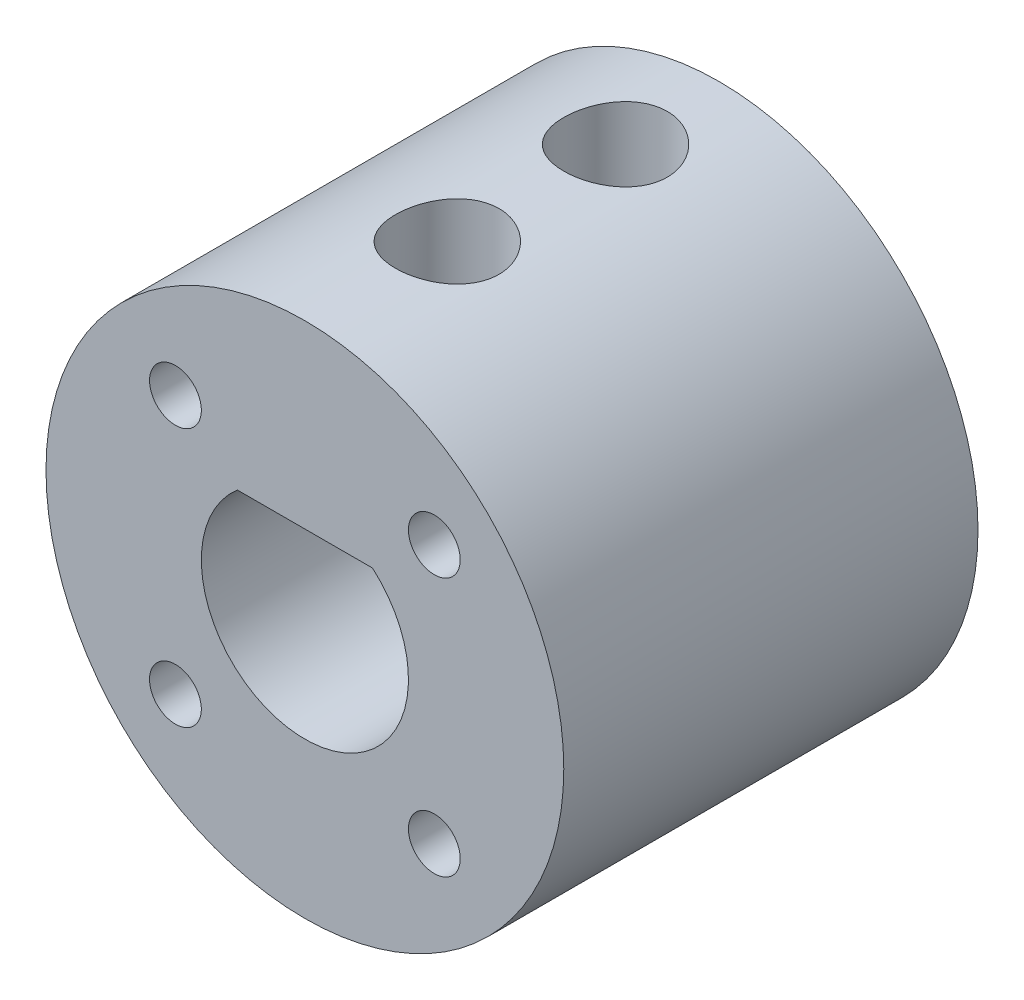
from build123d import *

# Parameters (mm, degrees)
CROQUIS1_R              = 10
SALIENTE_EXTRUIR1_DEPTH = 16
CROQUIS2_R              = 2
CORTAR_EXTRUIR1_DEPTH   = 20
CORTAR_EXTRUIR2_DEPTH   = 3
CROQUIS5_R              = 1
CORTAR_EXTRUIR3_DEPTH   = 14.0000001


with BuildPart() as part:
    # Croquis1 → Saliente-Extruir1 (new body)
    with BuildSketch(Plane.XY):
        Circle(CROQUIS1_R)
        with BuildLine():
            Line((2.611340652, 3.03), (-2.611340652, 3.03))
            ThreePointArc((-2.611340652, 3.03), (0, -4), (2.611340652, 3.03))
        make_face(mode=Mode.SUBTRACT)
    extrude(amount=SALIENTE_EXTRUIR1_DEPTH)

    # Croquis2 → Cortar-Extruir1 (cut)
    with BuildSketch(Plane(origin=(0, 0, 0), x_dir=(1, 0, 0), z_dir=(0, 1, 0))):
        with Locations((0, -4)):
            Circle(CROQUIS2_R)
        with Locations((0, -10.5)):
            Circle(CROQUIS2_R)
    extrude(amount=CORTAR_EXTRUIR1_DEPTH, mode=Mode.SUBTRACT)

    # Croquis3 → Cortar-Extruir2 (cut)
    with BuildSketch(Plane(origin=(0, 0, 0), x_dir=(-1, 0, 0), z_dir=(0, 0, -1))):
        Polygon((-3.5, 5), (-4.25, 6.299038106), (-5.75, 6.299038106), (-6.5, 5), (-5.75, 3.700961894), (-4.25, 3.700961894), align=None)
        Polygon((6.499503191, 5.038602866), (5.716320533, 6.317909289), (4.216817342, 6.279306423), (3.500496809, 4.961397134), (4.283679467, 3.682090711), (5.783182658, 3.720693577), align=None)
        Polygon((6.499999707, -5.000936904), (5.750811237, -3.7014306), (4.250811529, -3.700493696), (3.500000293, -4.999063096), (4.249188763, -6.2985694), (5.749188471, -6.299506304), align=None)
        Polygon((-3.500204706, -4.975219447), (-4.271562941, -3.688748898), (-5.771358235, -3.713529451), (-6.499795294, -5.024780553), (-5.728437059, -6.311251102), (-4.228641765, -6.286470549), align=None)
    extrude(amount=-CORTAR_EXTRUIR2_DEPTH, mode=Mode.SUBTRACT)

    # Croquis5 → Cortar-Extruir3 (cut, through all)
    with BuildSketch(Plane(origin=(0, 0, 3), x_dir=(-1, 0, 0), z_dir=(0, 0, -1))):
        with Locations((-5, 5)):
            Circle(CROQUIS5_R)
        with Locations((5, 5)):
            Circle(CROQUIS5_R)
        with Locations((5.000811383, -4.999063096)):
            Circle(CROQUIS5_R)
        with Locations((-5, -4.999063096)):
            Circle(CROQUIS5_R)
    extrude(amount=-CORTAR_EXTRUIR3_DEPTH, mode=Mode.SUBTRACT)


solid = part.part
